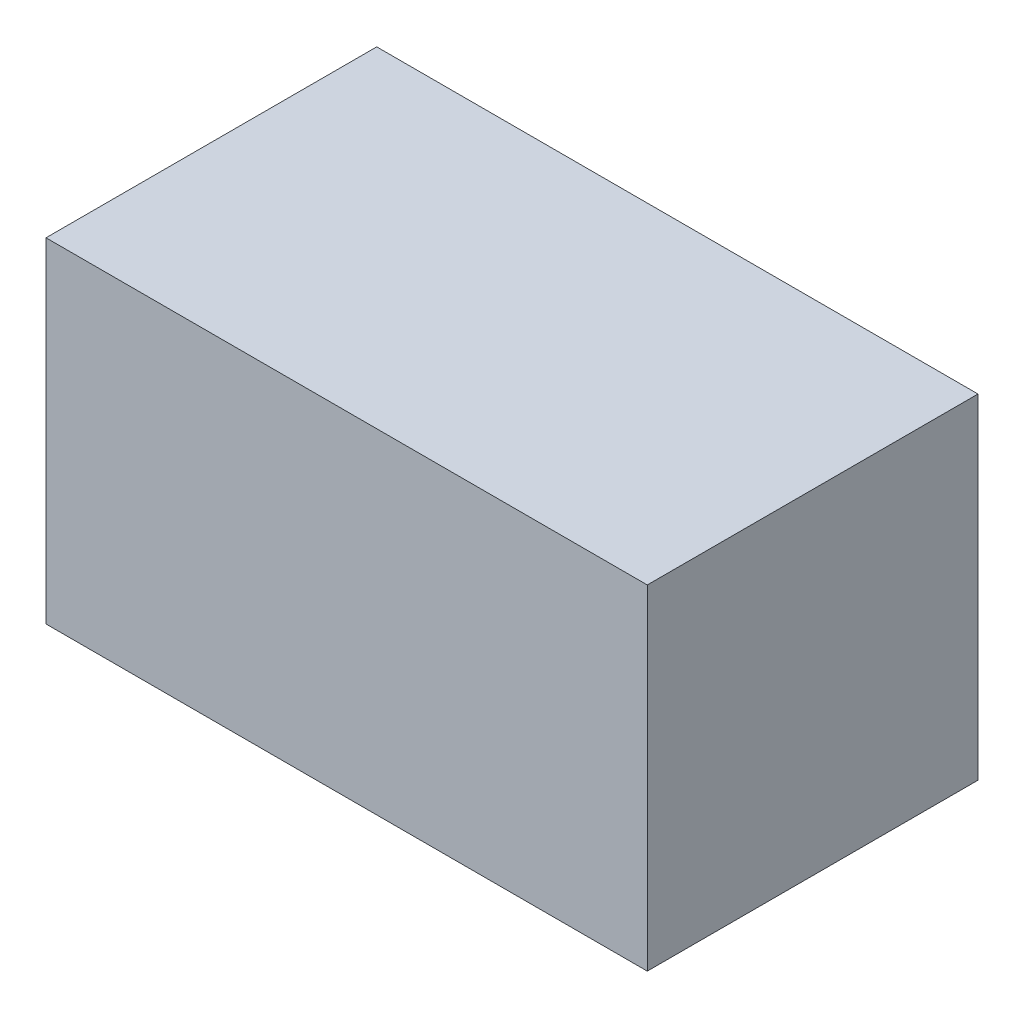
from build123d import *

# Parameters (mm, degrees)
SKETCH2_W           = 16
SKETCH2_H           = 8.8
BOSS_EXTRUDE1_DEPTH = 8.9


with BuildPart() as part:
    # Sketch2 → Boss-Extrude1 (new body)
    with BuildSketch(Plane(origin=(0, 0, 0), x_dir=(1, 0, 0), z_dir=(0, 1, 0))):
        Rectangle(SKETCH2_W, SKETCH2_H)
    extrude(amount=BOSS_EXTRUDE1_DEPTH)


solid = part.part
